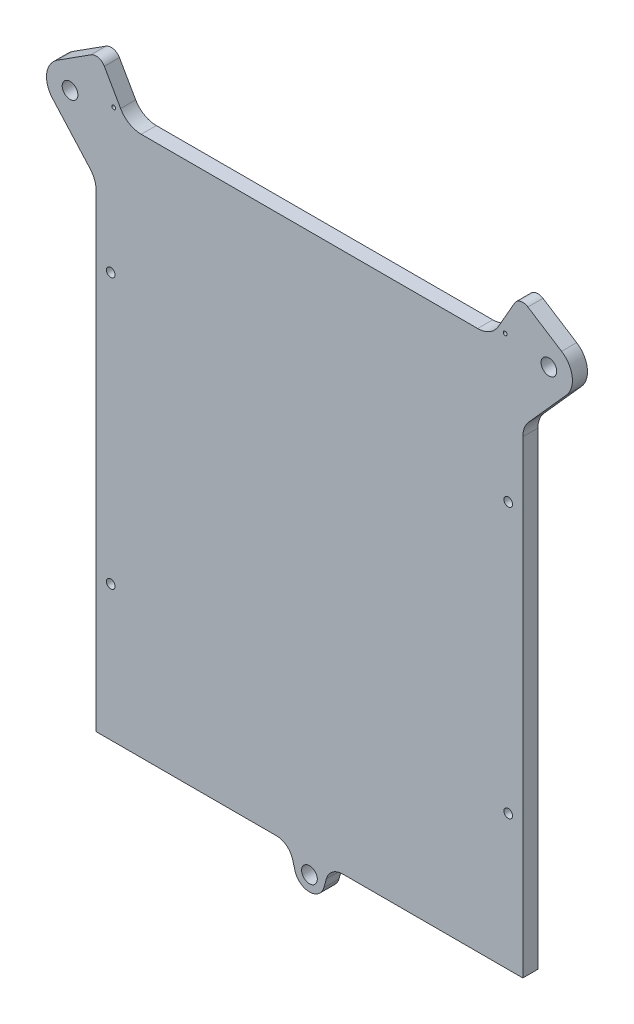
from build123d import *

# Parameters (mm, degrees)
SKETCH1_R                                  = 3.302
SKETCH1_R_2                                = 0.8
SKETCH1_R_3                                = 1.8288
PLATE_DEPTH                                = 6.35
WEIGHT_SAVING_CUTS_DEPTH                   = 3.81
WEIGHT_SAVING_CUT_FILLETS_R                = 7.112
WEIGHT_SAVING_CUT_FILLETS_OF_WEIGHT_SAVI_R = 7.112


with BuildPart() as part:
    # Sketch1 → Plate (new body)
    with BuildSketch(Plane.XY):
        with BuildLine():
            ThreePointArc((-92.41454916, 90.390466105), (-90.529528169, 87.293813231), (-89.872400011, 83.728599949))
            Line((-89.872400011, 83.728599949), (-89.872400011, -113.728599949))
            Line((-89.872400011, -113.728599949), (-13.969765558, -113.728599949))
            ThreePointArc((-13.969765558, -113.728599949), (-9.672797049, -115.173448492), (-7.12174212, -118.920933572))
            Line((-7.12174212, -118.920933572), (-6.06808826, -122.679631657))
            ThreePointArc((-6.06808826, -122.679631657), (-3.807578113, -126.000308116), (0, -127.280599949))
            Line((0, -127.280599949), (0, -124.280599949))
            ThreePointArc((0, -124.280599949), (-3.302, -120.978599949), (0, -117.676599949))
            Line((0, -117.676599949), (0, 113.728599949))
            Line((0, 113.728599949), (-70.872400011, 113.728599949))
            ThreePointArc((-70.872400011, 113.728599949), (-75.894449931, 115.081113921), (-79.558021314, 118.772797028))
            Line((-79.558021314, 118.772797028), (-86.39815149, 130.760921117))
            ThreePointArc((-86.39815149, 130.760921117), (-88.915607296, 132.662483019), (-92.02827915, 132.147900342))
            Line((-92.02827915, 132.147900342), (-106.211434698, 123.072672373))
            ThreePointArc((-106.211434698, 123.072672373), (-110.686595056, 116.074115319), (-108.260147064, 108.129355334))
            Line((-108.260147064, 108.129355334), (-92.41454916, 90.390466105))
        make_face()
        with Locations((-100.872400011, 114.728599949)):
            Circle(SKETCH1_R, mode=Mode.SUBTRACT)
        with Locations((-82.452600011, 117.728599949)):
            Circle(SKETCH1_R_2, mode=Mode.SUBTRACT)
        with Locations((-83.72, -56.750000051)):
            Circle(SKETCH1_R_3, mode=Mode.SUBTRACT)
        with Locations((-83.72, 56.902399949)):
            Circle(SKETCH1_R_3, mode=Mode.SUBTRACT)
    plate = extrude(amount=-PLATE_DEPTH)

    # Plate Mirror: Plate across plane
    add(plate.mirror(Plane(origin=(0, 0, 0), x_dir=(0, 0, 1), z_dir=(1, 0, 0))))

    # Sketch2 → Weight Saving Cuts (cut)
    with BuildSketch(Plane.XY.offset(-6.35)):
        Polygon((-4, -52.750000051), (-71.028738776, -52.750000051), (-4, -7.31425078), align=None)
        Polygon((-4, -110.347555783), (-68.648884958, -60.750000051), (-4, -60.750000051), align=None)
        Polygon((-23.163651007, -105.728599949), (-79.72, -105.728599949), (-79.72, -62.33950402), align=None)
        Polygon((-79.91, -49.564541674), (-12.410965189, -3.81), (-79.91, -3.81), align=None)
        Polygon((-12.284928228, 3.81), (-79.91, 49.711527156), (-79.91, 3.81), align=None)
        Polygon((-4, 53.092399949), (-71.322809123, 53.092399949), (-4, 7.396038078), align=None)
        Polygon((-21.998091507, 64.902399949), (-75.72, 95.699068062), (-75.72, 64.902399949), align=None)
        Polygon((-4, 106.89580016), (-4, 63.806088559), (-79.165973641, 106.89580016), align=None)
    weight_saving_cuts = extrude(amount=WEIGHT_SAVING_CUTS_DEPTH, mode=Mode.SUBTRACT)

    # Weight Saving Cut Fillets
    weight_saving_cut_fillets_edges = [part.edges().sort_by_distance(p)[0] for p in [
        (-71.028738776, -52.750000051, -4.445),
        (-4, -52.750000051, -4.445),
        (-4, -7.31425078, -4.445),
        (-68.648884958, -60.750000051, -4.445),
        (-4, -110.347555783, -4.445),
        (-4, -60.750000051, -4.445),
        (-79.72, -105.728599949, -4.445),
        (-23.163651007, -105.728599949, -4.445),
        (-79.72, -62.33950402, -4.445),
        (-79.91, -49.564541674, -4.445),
        (-12.410965189, -3.81, -4.445),
        (-79.91, -3.81, -4.445),
        (-12.284928228, 3.81, -4.445),
        (-79.91, 49.711527156, -4.445),
        (-79.91, 3.81, -4.445),
        (-4, 53.092399949, -4.445),
        (-71.322809123, 53.092399949, -4.445),
        (-4, 7.396038078, -4.445),
        (-21.998091507, 64.902399949, -4.445),
        (-75.72, 95.699068062, -4.445),
        (-75.72, 64.902399949, -4.445),
        (-4, 63.806088559, -4.445),
        (-4, 106.89580016, -4.445),
        (-79.165973641, 106.89580016, -4.445),
    ]]
    fillet(weight_saving_cut_fillets_edges, radius=WEIGHT_SAVING_CUT_FILLETS_R)

    # Weight Saving Mirror: Weight Saving Cuts across plane
    add(weight_saving_cuts.mirror(Plane(origin=(0, 0, 0), x_dir=(0, 0, 1), z_dir=(1, 0, 0))), mode=Mode.SUBTRACT)

    # Weight Saving Cut Fillets of Weight Savi
    weight_saving_cut_fillets_of_weight_savi_edges = [part.edges().sort_by_distance(p)[0] for p in [
        (71.028738776, -52.750000051, -4.445),
        (4, -52.750000051, -4.445),
        (4, -7.31425078, -4.445),
        (68.648884958, -60.750000051, -4.445),
        (4, -110.347555783, -4.445),
        (4, -60.750000051, -4.445),
        (79.72, -105.728599949, -4.445),
        (23.163651007, -105.728599949, -4.445),
        (79.72, -62.33950402, -4.445),
        (79.91, -49.564541674, -4.445),
        (12.410965189, -3.81, -4.445),
        (79.91, -3.81, -4.445),
        (12.284928228, 3.81, -4.445),
        (79.91, 49.711527156, -4.445),
        (79.91, 3.81, -4.445),
        (4, 53.092399949, -4.445),
        (71.322809123, 53.092399949, -4.445),
        (4, 7.396038078, -4.445),
        (21.998091507, 64.902399949, -4.445),
        (75.72, 95.699068062, -4.445),
        (75.72, 64.902399949, -4.445),
        (4, 63.806088559, -4.445),
        (4, 106.89580016, -4.445),
        (79.165973641, 106.89580016, -4.445),
    ]]
    fillet(weight_saving_cut_fillets_of_weight_savi_edges, radius=WEIGHT_SAVING_CUT_FILLETS_OF_WEIGHT_SAVI_R)


solid = part.part
